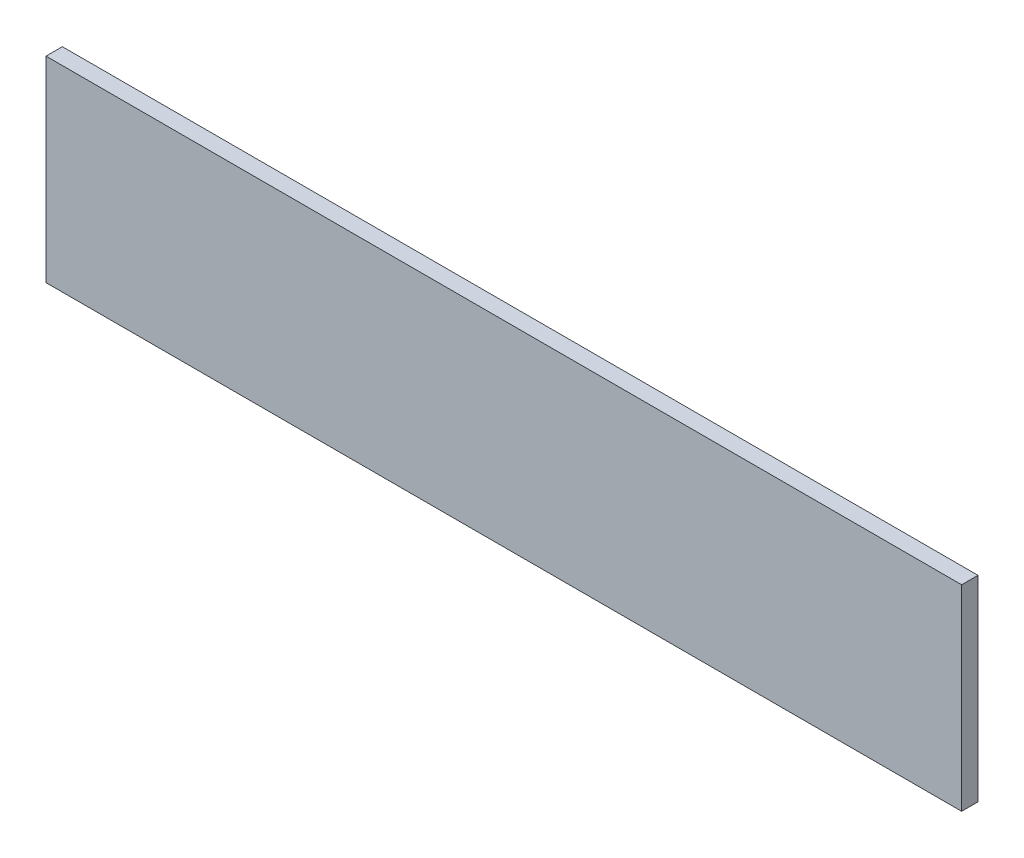
from build123d import *

# Parameters (mm, degrees)
SKETCH1_W           = 6.35
SKETCH1_H           = 76.2
BOSS_EXTRUDE1_DEPTH = 355.6


with BuildPart() as part:
    # Sketch1 → Boss-Extrude1 (new body)
    with BuildSketch(Plane(origin=(0, 0, 0), x_dir=(0, 0, -1), z_dir=(1, 0, 0))):
        Rectangle(SKETCH1_W, SKETCH1_H)
    extrude(amount=BOSS_EXTRUDE1_DEPTH)


solid = part.part
